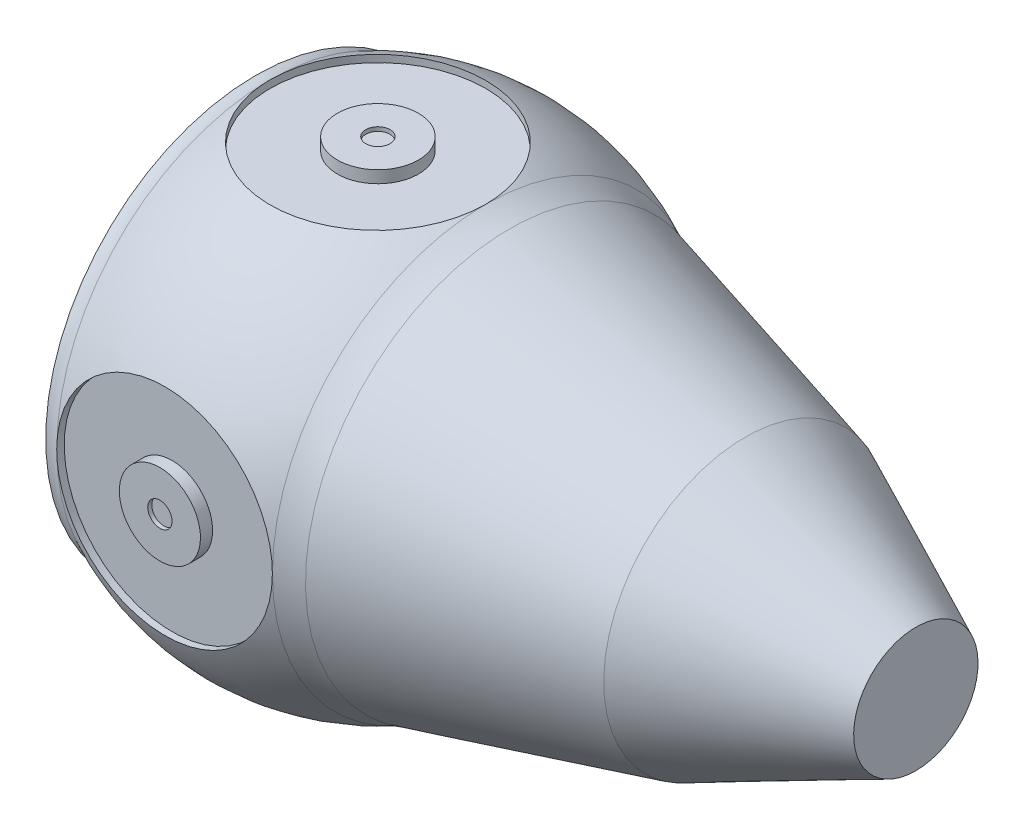
from build123d import *

# Parameters (mm, degrees)
ESCALA1_SCALE               = 0.2
PADR_OCIRCULAR1_COUNT       = 4
FURO_COM_FOLGA_DE_M61_D     = 6.6
FURO_COM_FOLGA_DE_M61_DEPTH = 15.999481013
FURO_COM_FOLGA_DE_M61_TIP   = 1.982840043


with BuildPart() as part:
    # Esboço1 → Revolução1 (revolve)
    with BuildSketch(Plane.XY, mode=Mode.PRIVATE) as revolu_o1_sk:
        with BuildLine():
            Line((3317.399667889, 0), (3317.399667889, 383.5))
            Line((3317.399667889, 383.5), (2265.399667889, 873))
            Line((2265.399667889, 873), (813.399667889, 1260))
            ThreePointArc((813.399667889, 1260), (737.813781205, 1284.220696189), (665, 1315.812176946))
            ThreePointArc((665, 1315.812176946), (0, 1471.161405015), (-665, 1315.812176946))
            ThreePointArc((-665, 1315.812176946), (-708.110967822, 1300.356342101), (-753.607594937, 1295.112746158))
            Line((-753.607594937, 1295.112746158), (-753.607594937, 1244.476357536))
            Line((-753.607594937, 1244.476357536), (25.002405063, 1244.476357536))
            Line((25.002405063, 1244.476357536), (25.002405063, 1164.476357536))
            Line((25.002405063, 1164.476357536), (55.002405063, 1164.476357536))
            Line((55.002405063, 1164.476357536), (55.002405063, 1244.476357536))
            Line((55.002405063, 1244.476357536), (813.399667889, 1244.476357536))
            Line((813.399667889, 1244.476357536), (1370.201096416, 1096.072671007))
            Line((1370.201096416, 1096.072671007), (2260.264870662, 858.844929525))
            Line((2260.264870662, 858.844929525), (3302.399667889, 373.935249636))
            Line((3302.399667889, 373.935249636), (3302.399667889, 0))
            Line((3302.399667889, 0), (3317.399667889, 0))
        make_face()
    revolve(revolu_o1_sk.sketch.rotate(Axis((-14.7457766, 0, 0), (1, 0, 0)), 180), axis=Axis((-14.7457766, 0, 0), (1, 0, 0)))


with BuildPart() as part_1:
    # Escala1: scaled about (0, 0, 0)
    add(part.part.scale(ESCALA1_SCALE))

    # Esboço2 → Corte-Revolução9 (revolve, cut)
    with BuildSketch(Plane.XY, mode=Mode.PRIVATE) as corte_revolu_o9_sk:
        Polygon((15, 268.895271507), (15, 263.895271507), (0, 263.895271507), (0, 311.146389703), (133, 311.146389703), (133, 253.895271507), (50, 253.895271507), (50, 268.895271507), align=None)
    corte_revolu_o9 = revolve(corte_revolu_o9_sk.sketch.rotate(Axis((0, -141.14012245, 0), (0, 1, 0)), 90), axis=Axis((0, -141.14012245, 0), (0, 1, 0)), mode=Mode.SUBTRACT)

    # PadrãoCircular1: Corte-Revolução9 ×4 about axis
    padr_ocircular1_axis = Axis((0, 0, 0), (1, 0, 0))
    for i in range(1, PADR_OCIRCULAR1_COUNT):
        add(corte_revolu_o9.rotate(padr_ocircular1_axis, i * 360 / PADR_OCIRCULAR1_COUNT), mode=Mode.SUBTRACT)

    # Furo com folga de M61
    with Locations(Plane(origin=(11.000481013, 0, 0), x_dir=(0, 0, -1), z_dir=(1, 0, 0))):
        with Locations((0, 240.895271507), (240.895271507, 0), (0, -240.895271507), (-240.895271507, 0), (0, 0)):
            Hole(FURO_COM_FOLGA_DE_M61_D / 2, depth=FURO_COM_FOLGA_DE_M61_DEPTH)
            with Locations((0, 0, -(FURO_COM_FOLGA_DE_M61_DEPTH + FURO_COM_FOLGA_DE_M61_TIP / 2))):  # 118° drill point
                Cone(0, FURO_COM_FOLGA_DE_M61_D / 2, FURO_COM_FOLGA_DE_M61_TIP, mode=Mode.SUBTRACT)


solid = part_1.part
